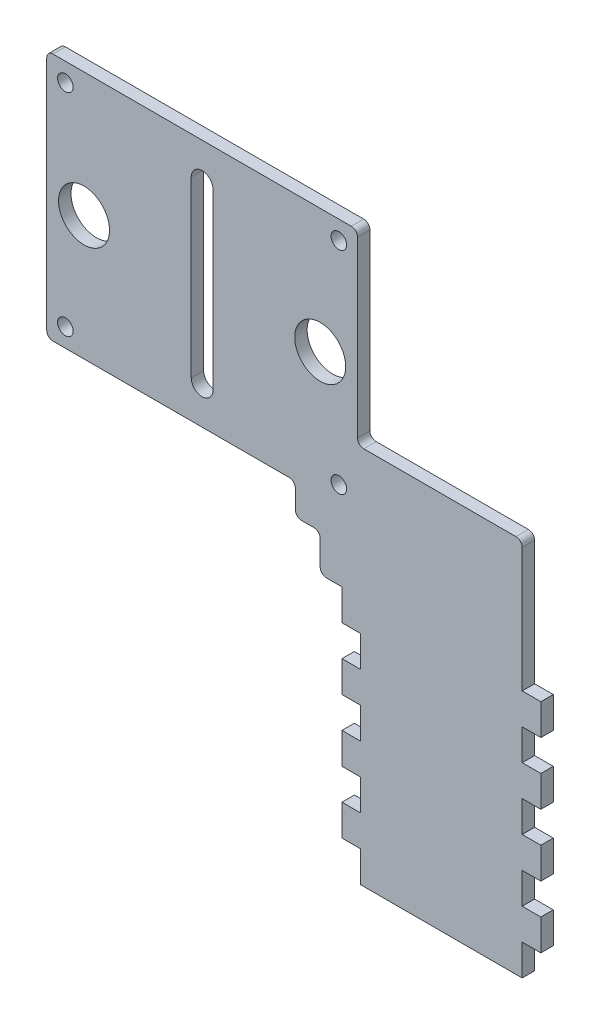
from build123d import *

# Parameters (mm, degrees)
PLATE_BODY_DEPTH     = 2
SKETCH2_R            = 4.1
SHAFT_BEARINGS_DEPTH = 3
SLOT_DEPTH           = 3
SKETCH5_R            = 1.25
BOLT_HOLES_DEPTH     = 3
SKETCH6_W            = 0.5
SKETCH6_H            = 40
CUT_EXTRUDE1_DEPTH   = 3
SKETCH8_W            = 3
SKETCH8_H            = 5
FINGER_JOINTS_DEPTH  = 2
F_1MM_FILLETS_R      = 1


with BuildPart() as part:
    # Sketch1 → plate_body (new body)
    with BuildSketch(Plane.XY):
        Polygon((0, 40), (0, 0), (40, 0), (40, -5), (44, -5), (44, -11), (50, -11), (50, -51), (76.5, -51), (76.5, 10), (50, 10), (50, 40), align=None)
    extrude(amount=PLATE_BODY_DEPTH)

    # Sketch2 → shaft_bearings (cut, through all)
    with BuildSketch(Plane.XY.offset(2)):
        with Locations((6, 20)):
            Circle(SKETCH2_R)
        with Locations((44, 20)):
            Circle(SKETCH2_R)
    extrude(amount=-SHAFT_BEARINGS_DEPTH, mode=Mode.SUBTRACT)

    # Sketch4 → slot (cut, through all)
    with BuildSketch(Plane.XY.offset(2)):
        with BuildLine():
            Line((26.75, 34), (26.75, 6))
            ThreePointArc((26.75, 6), (25, 4.25), (23.25, 6))
            Line((23.25, 6), (23.25, 34))
            ThreePointArc((23.25, 34), (25, 35.75), (26.75, 34))
        make_face()
    extrude(amount=-SLOT_DEPTH, mode=Mode.SUBTRACT)

    # Sketch5 → bolt_holes (cut, through all)
    with BuildSketch(Plane.XY.offset(2)):
        with Locations((3, 37)):
            Circle(SKETCH5_R)
        with Locations((47, 37)):
            Circle(SKETCH5_R)
        with Locations((3, 3)):
            Circle(SKETCH5_R)
        with Locations((47, 3)):
            Circle(SKETCH5_R)
    extrude(amount=-BOLT_HOLES_DEPTH, mode=Mode.SUBTRACT)

    # Sketch6 → Cut-Extrude1 (cut, through all)
    with BuildSketch(Plane.XY.offset(2)):
        with Locations((50.25, -31)):
            Rectangle(SKETCH6_W, SKETCH6_H)
    extrude(amount=-CUT_EXTRUDE1_DEPTH, mode=Mode.SUBTRACT)

    # Sketch8 → finger_joints (add)
    with BuildSketch(Plane.XY.offset(2)):
        with Locations((49, -33.5)):
            Rectangle(SKETCH8_W, SKETCH8_H)
        with Locations((49, -43.5)):
            Rectangle(SKETCH8_W, SKETCH8_H)
        with Locations((78, -43.5)):
            Rectangle(SKETCH8_W, SKETCH8_H)
        with Locations((78, -33.5)):
            Rectangle(SKETCH8_W, SKETCH8_H)
        with Locations((49, -13.5)):
            Rectangle(SKETCH8_W, SKETCH8_H)
        with Locations((49, -23.5)):
            Rectangle(SKETCH8_W, SKETCH8_H)
        with Locations((78, -23.5)):
            Rectangle(SKETCH8_W, SKETCH8_H)
        with Locations((78, -13.5)):
            Rectangle(SKETCH8_W, SKETCH8_H)
    extrude(amount=-FINGER_JOINTS_DEPTH)

    # 1mm_fillets
    f_1mm_fillets_edges = [part.edges().sort_by_distance(p)[0] for p in [
        (44, -11, 1),
        (44, -5, 1),
        (40, -5, 1),
        (40, 0, 1),
        (0, 0, 1),
        (0, 40, 1),
        (50, 40, 1),
        (50, 10, 1),
        (76.5, 10, 1),
    ]]
    fillet(f_1mm_fillets_edges, radius=F_1MM_FILLETS_R)


solid = part.part
